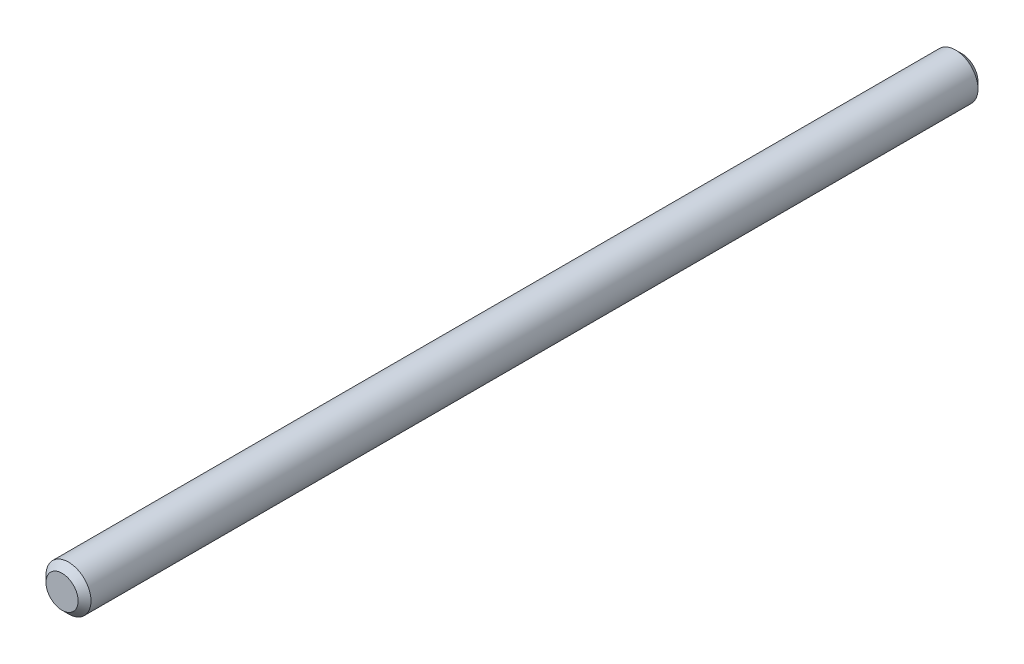
from build123d import *

# Parameters (mm, degrees)
SKETCH1_R           = 1.75
BOSS_EXTRUDE1_DEPTH = 70
CHAMFER1_SIZE       = 0.5


with BuildPart() as part:
    # Sketch1 → Boss-Extrude1 (new body)
    with BuildSketch(Plane.XY):
        Circle(SKETCH1_R)
    extrude(amount=BOSS_EXTRUDE1_DEPTH)

    # Chamfer1
    chamfer1_edges = [part.edges().sort_by_distance(p)[0] for p in [
        (-1.75, 0, 0),
        (-1.75, 0, 70),
    ]]
    chamfer(chamfer1_edges, length=CHAMFER1_SIZE)


solid = part.part
